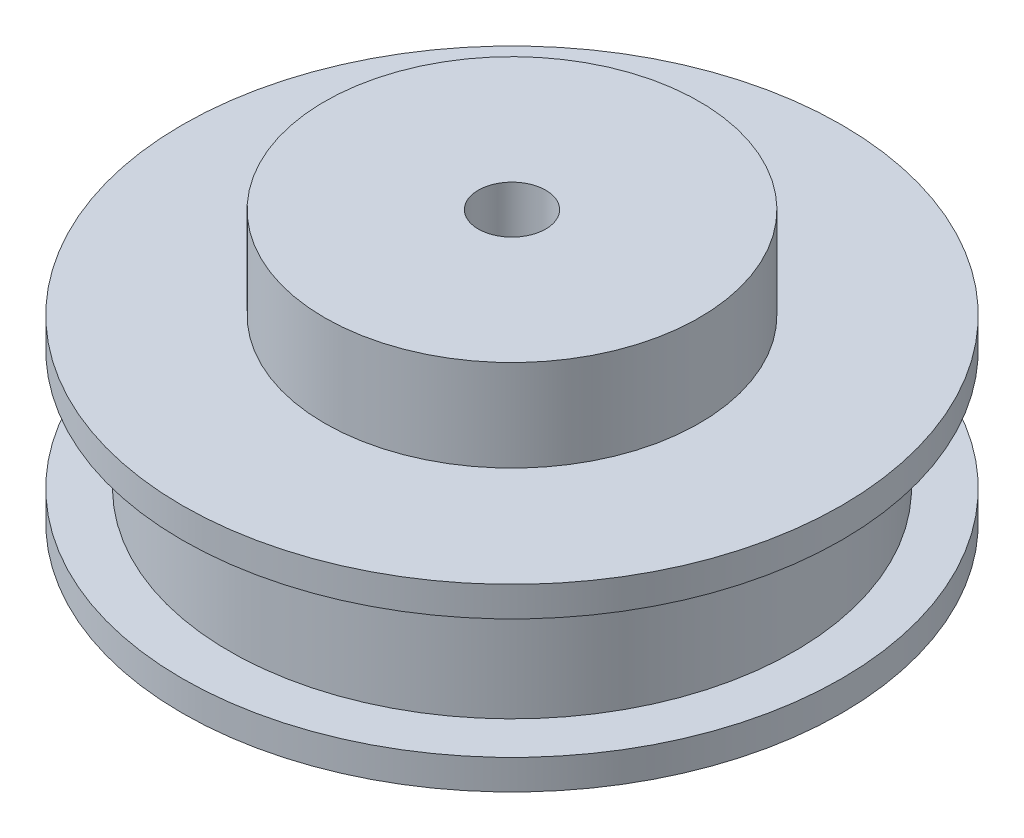
from build123d import *

# Parameters (mm, degrees)
SKETCH1_R           = 22
BOSS_EXTRUDE1_DEPTH = 10
SKETCH2_R           = 12.5
BOSS_EXTRUDE2_DEPTH = 6.1
SKETCH3_R           = 22
SKETCH3_R_2         = 18.85
CUT_EXTRUDE2_DEPTH  = 8
SKETCH5_R           = 22
BOSS_EXTRUDE3_DEPTH = 2
SKETCH6_R           = 2.25
CUT_EXTRUDE3_DEPTH  = 28


with BuildPart() as part:
    # Sketch1 → Boss-Extrude1 (new body)
    with BuildSketch(Plane(origin=(0, 0, 0), x_dir=(1, 0, 0), z_dir=(0, 1, 0))):
        Circle(SKETCH1_R)
    extrude(amount=BOSS_EXTRUDE1_DEPTH)

    # Sketch2 → Boss-Extrude2 (add)
    with BuildSketch(Plane(origin=(0, 10, 0), x_dir=(1, 0, 0), z_dir=(0, 1, 0))):
        Circle(SKETCH2_R)
    extrude(amount=BOSS_EXTRUDE2_DEPTH)

    # Sketch3 → Cut-Extrude2 (cut)
    with BuildSketch(Plane.XZ):
        Circle(SKETCH3_R)
        Circle(SKETCH3_R_2, mode=Mode.SUBTRACT)
    extrude(amount=-CUT_EXTRUDE2_DEPTH, mode=Mode.SUBTRACT)

    # Sketch5 → Boss-Extrude3 (add)
    with BuildSketch(Plane.XZ):
        Circle(SKETCH5_R)
    extrude(amount=BOSS_EXTRUDE3_DEPTH)

    # Sketch6 → Cut-Extrude3 (cut)
    with BuildSketch(Plane.XZ.offset(2)):
        Circle(SKETCH6_R)
    extrude(amount=-CUT_EXTRUDE3_DEPTH, mode=Mode.SUBTRACT)


solid = part.part
